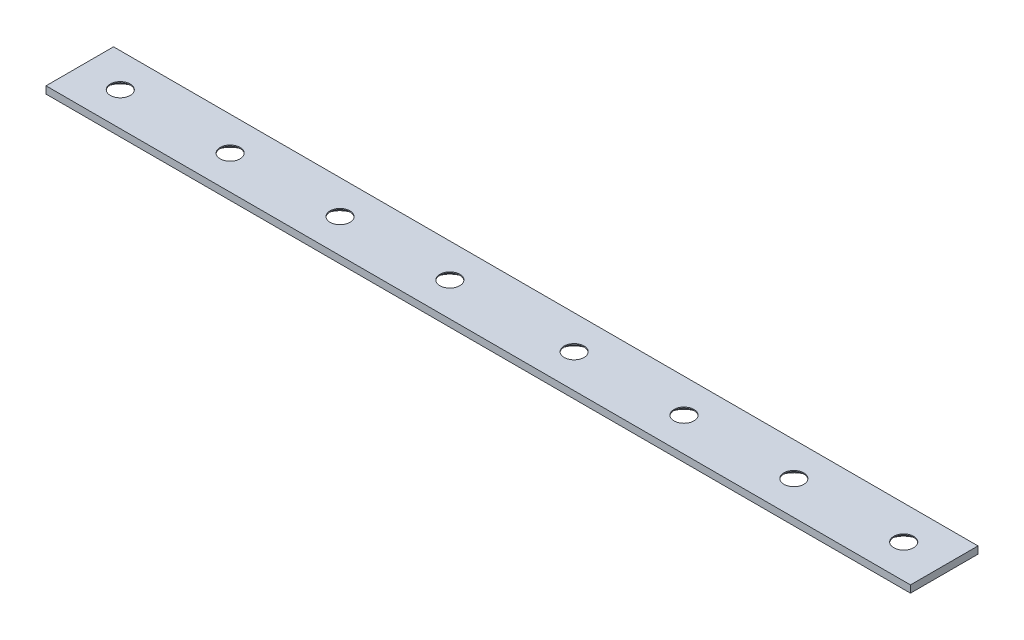
from build123d import *

# Parameters (mm, degrees)
SKETCH1_W                                  = 243.84
SKETCH1_H                                  = 19.05
BOSS_EXTRUDE1_DEPTH                        = 2.032
CSK_FOR_10_FLAT_HEAD_MACHINE_SCREW_2_COUNT = 2
CSK_FOR_10_FLAT_HEAD_MACHINE_SCREW_2_PITCH = 30.988
CSK_FOR_10_FLAT_HEAD_MACHINE_SCREW_3_COUNT = 2
CSK_FOR_10_FLAT_HEAD_MACHINE_SCREW_3_PITCH = 61.976
CSK_FOR_10_FLAT_HEAD_MACHINE_SCREW_4_COUNT = 2
CSK_FOR_10_FLAT_HEAD_MACHINE_SCREW_4_PITCH = 92.964
CSK_FOR_10_FLAT_HEAD_MACHINE_SCREW_5_COUNT = 2
CSK_FOR_10_FLAT_HEAD_MACHINE_SCREW_5_PITCH = 128.016
CSK_FOR_10_FLAT_HEAD_MACHINE_SCREW_6_COUNT = 2
CSK_FOR_10_FLAT_HEAD_MACHINE_SCREW_6_PITCH = 159.004
CSK_FOR_10_FLAT_HEAD_MACHINE_SCREW_7_COUNT = 2
CSK_FOR_10_FLAT_HEAD_MACHINE_SCREW_7_PITCH = 189.992
CSK_FOR_10_FLAT_HEAD_MACHINE_SCREW_8_COUNT = 2
CSK_FOR_10_FLAT_HEAD_MACHINE_SCREW_8_PITCH = 220.98


with BuildPart() as part:
    # Sketch1 → Boss-Extrude1 (new body)
    with BuildSketch(Plane(origin=(0, 0, 0), x_dir=(1, 0, 0), z_dir=(0, 1, 0))):
        with Locations((121.92, 9.525)):
            Rectangle(SKETCH1_W, SKETCH1_H)
    extrude(amount=BOSS_EXTRUDE1_DEPTH)

    # Sketch3 → CSK for #10 Flat Head Machine Screw (100)1 (revolve, cut)
    with BuildSketch(Plane(origin=(11.43, 0, -9.525), x_dir=(0, 0, -1), z_dir=(1, 0, 0))):
        Polygon((0, 0), (0, 2.032), (2.8067, 2.032), (2.8067, 1.747676712), (4.8895, 0), align=None)
    csk_for_10_flat_head_machine_screw_100 = revolve(axis=Axis((11.43, -6.35, -9.525), (0, 1, 0)), mode=Mode.SUBTRACT)

    # CSK for _10 Flat Head Machine Screw  2: CSK for #10 Flat Head Machine Screw (100)1 ×2
    with Locations(*[(i * CSK_FOR_10_FLAT_HEAD_MACHINE_SCREW_2_PITCH, 0, 0) for i in range(1, CSK_FOR_10_FLAT_HEAD_MACHINE_SCREW_2_COUNT)]):
        add(csk_for_10_flat_head_machine_screw_100, mode=Mode.SUBTRACT)

    # CSK for _10 Flat Head Machine Screw  3: CSK for #10 Flat Head Machine Screw (100)1 ×2
    with Locations(*[(i * CSK_FOR_10_FLAT_HEAD_MACHINE_SCREW_3_PITCH, 0, 0) for i in range(1, CSK_FOR_10_FLAT_HEAD_MACHINE_SCREW_3_COUNT)]):
        add(csk_for_10_flat_head_machine_screw_100, mode=Mode.SUBTRACT)

    # CSK for _10 Flat Head Machine Screw  4: CSK for #10 Flat Head Machine Screw (100)1 ×2
    with Locations(*[(i * CSK_FOR_10_FLAT_HEAD_MACHINE_SCREW_4_PITCH, 0, 0) for i in range(1, CSK_FOR_10_FLAT_HEAD_MACHINE_SCREW_4_COUNT)]):
        add(csk_for_10_flat_head_machine_screw_100, mode=Mode.SUBTRACT)

    # CSK for _10 Flat Head Machine Screw  5: CSK for #10 Flat Head Machine Screw (100)1 ×2
    with Locations(*[(i * CSK_FOR_10_FLAT_HEAD_MACHINE_SCREW_5_PITCH, 0, 0) for i in range(1, CSK_FOR_10_FLAT_HEAD_MACHINE_SCREW_5_COUNT)]):
        add(csk_for_10_flat_head_machine_screw_100, mode=Mode.SUBTRACT)

    # CSK for _10 Flat Head Machine Screw  6: CSK for #10 Flat Head Machine Screw (100)1 ×2
    with Locations(*[(i * CSK_FOR_10_FLAT_HEAD_MACHINE_SCREW_6_PITCH, 0, 0) for i in range(1, CSK_FOR_10_FLAT_HEAD_MACHINE_SCREW_6_COUNT)]):
        add(csk_for_10_flat_head_machine_screw_100, mode=Mode.SUBTRACT)

    # CSK for _10 Flat Head Machine Screw  7: CSK for #10 Flat Head Machine Screw (100)1 ×2
    with Locations(*[(i * CSK_FOR_10_FLAT_HEAD_MACHINE_SCREW_7_PITCH, 0, 0) for i in range(1, CSK_FOR_10_FLAT_HEAD_MACHINE_SCREW_7_COUNT)]):
        add(csk_for_10_flat_head_machine_screw_100, mode=Mode.SUBTRACT)

    # CSK for _10 Flat Head Machine Screw  8: CSK for #10 Flat Head Machine Screw (100)1 ×2
    with Locations(*[(i * CSK_FOR_10_FLAT_HEAD_MACHINE_SCREW_8_PITCH, 0, 0) for i in range(1, CSK_FOR_10_FLAT_HEAD_MACHINE_SCREW_8_COUNT)]):
        add(csk_for_10_flat_head_machine_screw_100, mode=Mode.SUBTRACT)


solid = part.part
